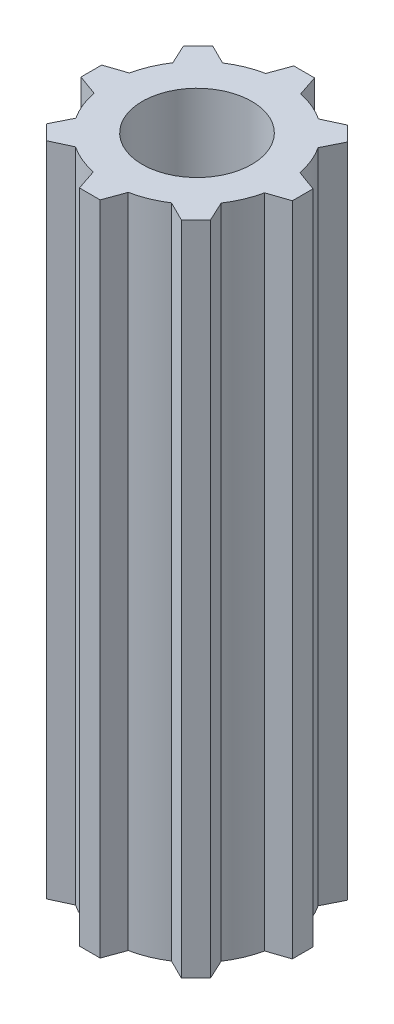
from build123d import *

# Parameters (mm, degrees)
BOSS_EXTRUDE1_DEPTH = 38.1
SKETCH2_R           = 3.175
CUT_EXTRUDE1_DEPTH  = 39.1


with BuildPart() as part:
    # Sketch1 → Boss-Extrude1 (new body)
    with BuildSketch(Plane(origin=(0, 0, 0), x_dir=(1, 0, 0), z_dir=(0, 1, 0))):
        with BuildLine():
            Line((1.047492977, 4.970830762), (0.644904142, 6.175331583))
            Line((0.644904142, 6.175331583), (-0.556834652, 6.175331583))
            Line((-0.556834652, 6.175331583), (-0.991979734, 4.982205958))
            ThreePointArc((-0.991979734, 4.982205958), (-1.917824995, 4.70407773), (-2.774218752, 4.255597527))
            Line((-2.774218752, 4.255597527), (-3.910602747, 4.822634931))
            Line((-3.910602747, 4.822634931), (-4.760360397, 3.97287728))
            Line((-4.760360397, 3.97287728), (-4.224387215, 2.821516022))
            ThreePointArc((-4.224387215, 2.821516022), (-4.682392321, 1.970178203), (-4.970830762, 1.047492977))
            Line((-4.970830762, 1.047492977), (-6.175331583, 0.644904142))
            Line((-6.175331583, 0.644904142), (-6.175331583, -0.556834652))
            Line((-6.175331583, -0.556834652), (-4.982205958, -0.991979734))
            ThreePointArc((-4.982205958, -0.991979734), (-4.70407773, -1.917824995), (-4.255597527, -2.774218752))
            Line((-4.255597527, -2.774218752), (-4.822634931, -3.910602747))
            Line((-4.822634931, -3.910602747), (-3.97287728, -4.760360397))
            Line((-3.97287728, -4.760360397), (-2.821516022, -4.224387215))
            ThreePointArc((-2.821516022, -4.224387215), (-1.970178203, -4.682392321), (-1.047492977, -4.970830762))
            Line((-1.047492977, -4.970830762), (-0.644904142, -6.175331583))
            Line((-0.644904142, -6.175331583), (0.556834652, -6.175331583))
            Line((0.556834652, -6.175331583), (0.991979734, -4.982205958))
            ThreePointArc((0.991979734, -4.982205958), (1.917824995, -4.70407773), (2.774218752, -4.255597527))
            Line((2.774218752, -4.255597527), (3.910602747, -4.822634931))
            Line((3.910602747, -4.822634931), (4.760360397, -3.97287728))
            Line((4.760360397, -3.97287728), (4.224387215, -2.821516022))
            ThreePointArc((4.224387215, -2.821516022), (4.682392321, -1.970178203), (4.970830762, -1.047492977))
            Line((4.970830762, -1.047492977), (6.175331583, -0.644904142))
            Line((6.175331583, -0.644904142), (6.175331583, 0.556834652))
            Line((6.175331583, 0.556834652), (4.982205958, 0.991979734))
            ThreePointArc((4.982205958, 0.991979734), (4.70407773, 1.917824995), (4.255597527, 2.774218752))
            Line((4.255597527, 2.774218752), (4.822634931, 3.910602747))
            Line((4.822634931, 3.910602747), (3.97287728, 4.760360397))
            Line((3.97287728, 4.760360397), (2.821516022, 4.224387215))
            ThreePointArc((2.821516022, 4.224387215), (1.970178203, 4.682392321), (1.047492977, 4.970830762))
        make_face()
    extrude(amount=BOSS_EXTRUDE1_DEPTH)

    # Sketch2 → Cut-Extrude1 (cut, through all)
    with BuildSketch(Plane(origin=(0, 38.1, 0), x_dir=(1, 0, 0), z_dir=(0, 1, 0))):
        Circle(SKETCH2_R)
    extrude(amount=-CUT_EXTRUDE1_DEPTH, mode=Mode.SUBTRACT)


solid = part.part
